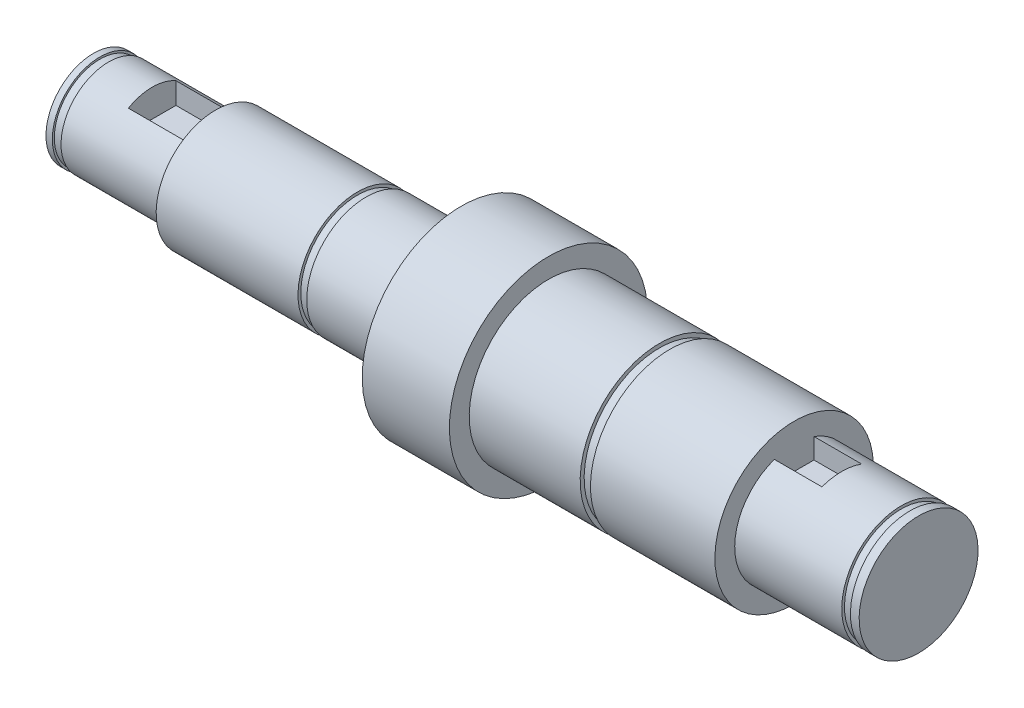
from build123d import *

# Parameters (mm, degrees)
SKETCH3_W          = 6
SKETCH3_H          = 3.5
CUT_EXTRUDE1_DEPTH = 8
SKETCH4_W          = 5
SKETCH4_H          = 3
CUT_EXTRUDE3_DEPTH = 6


with BuildPart() as part:
    # Sketch1 → Revolve1 (revolve)
    with BuildSketch(Plane.XY):
        Polygon((-52.05, 0), (52.05, 0), (52.05, 7.5), (50.95, 7.5), (50.95, 7.15), (49.85, 7.15), (49.85, 7.5), (36.35, 7.5), (36.35, 10), (20.65, 10), (20.65, 9.5), (19.35, 9.5), (19.35, 10), (5.35, 10), (5.35, 12.5), (-5.65, 12.5), (-5.65, 7.5), (-17.65, 7.5), (-17.65, 7.15), (-18.75, 7.15), (-18.75, 7.5), (-36.65, 7.5), (-36.65, 6), (-50.15, 6), (-50.15, 5.75), (-51.25, 5.75), (-51.25, 6), (-52.05, 6), align=None)
    revolve(axis=Axis((-52.05, 0, 0), (1, 0, 0)))

    # Sketch3 → Cut-Extrude1 (cut)
    with BuildSketch(Plane.ZY.offset(36.65)):
        with Locations((0, 4.25)):
            Rectangle(SKETCH3_W, SKETCH3_H)
    extrude(amount=CUT_EXTRUDE1_DEPTH, mode=Mode.SUBTRACT)

    # Sketch4 → Cut-Extrude3 (cut)
    with BuildSketch(Plane(origin=(36.35, 0, 0), x_dir=(0, 0, -1), z_dir=(1, 0, 0))):
        with Locations((0, 6)):
            Rectangle(SKETCH4_W, SKETCH4_H)
    extrude(amount=CUT_EXTRUDE3_DEPTH, mode=Mode.SUBTRACT)


solid = part.part
